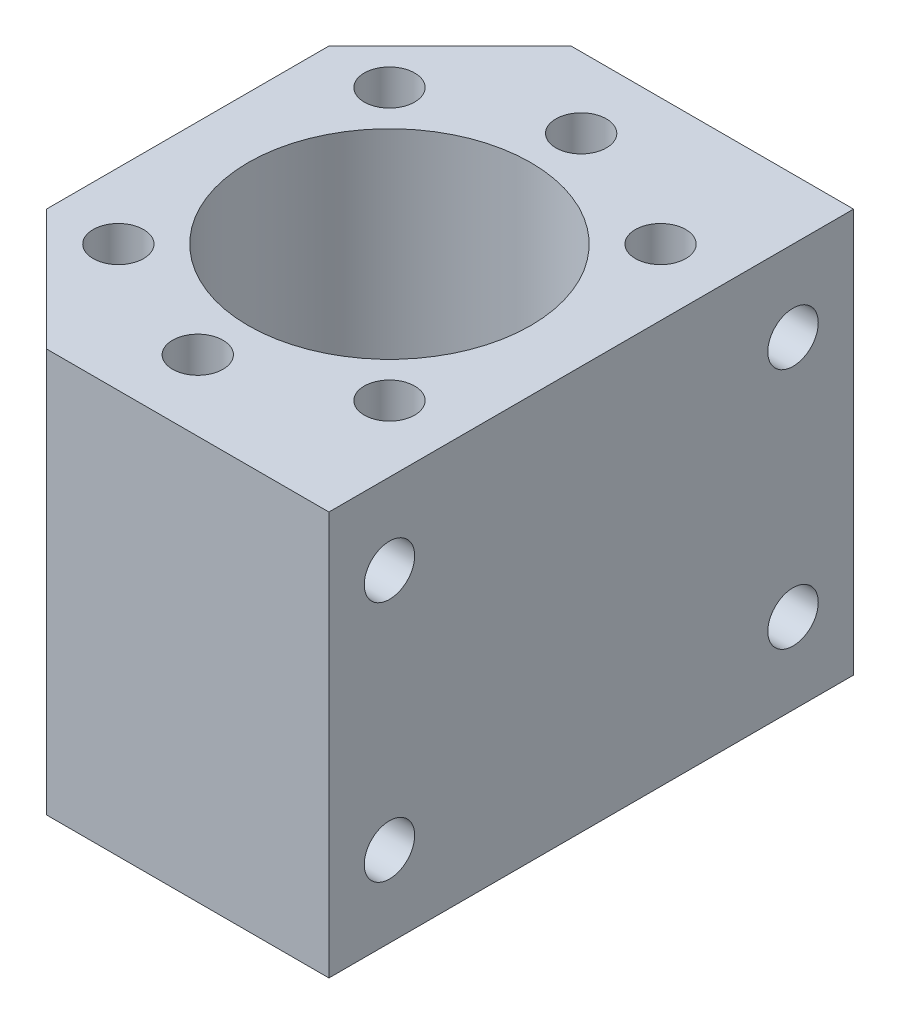
from build123d import *

# Parameters (mm, degrees)
SKETCH_1_R          = 14
EXTRUDE_1_DEPTH     = 40
SKETCH_2_R          = 2.5
CUT_EXTRUDE_1_DEPTH = 10
SKETCH_3_R          = 2.5
CUT_EXTRUDE_2_DEPTH = 10


with BuildPart() as part:
    # Эскиз1 → Бобышка-Вытянуть1 (new body)
    with BuildSketch(Plane(origin=(0, 0, 0), x_dir=(1, 0, 0), z_dir=(0, 1, 0))):
        Polygon((-20, 14), (-8, 26), (20, 26), (20, -26), (-8, -26), (-20, -14), align=None)
        Circle(SKETCH_1_R, mode=Mode.SUBTRACT)
    extrude(amount=EXTRUDE_1_DEPTH)

    # Эскиз2 → Вырез-Вытянуть1 (cut)
    with BuildSketch(Plane(origin=(0, 40, 0), x_dir=(1, 0, 0), z_dir=(0, 1, 0))):
        with Locations((0, 19)):
            Circle(SKETCH_2_R)
        with Locations((13.435028843, 13.435028843)):
            Circle(SKETCH_2_R)
        with Locations((13.435028843, -13.435028843)):
            Circle(SKETCH_2_R)
        with Locations((0, -19)):
            Circle(SKETCH_2_R)
        with Locations((-13.435028843, -13.435028843)):
            Circle(SKETCH_2_R)
        with Locations((-13.435028843, 13.435028843)):
            Circle(SKETCH_2_R)
    extrude(amount=-CUT_EXTRUDE_1_DEPTH, mode=Mode.SUBTRACT)

    # Эскиз3 → Вырез-Вытянуть2 (cut)
    with BuildSketch(Plane(origin=(20, 0, 0), x_dir=(0, 0, -1), z_dir=(1, 0, 0))):
        with Locations((-20, 32)):
            Circle(SKETCH_3_R)
        with Locations((20, 32)):
            Circle(SKETCH_3_R)
        with Locations((20, 8)):
            Circle(SKETCH_3_R)
        with Locations((-20, 8)):
            Circle(SKETCH_3_R)
    extrude(amount=-CUT_EXTRUDE_2_DEPTH, mode=Mode.SUBTRACT)


solid = part.part
